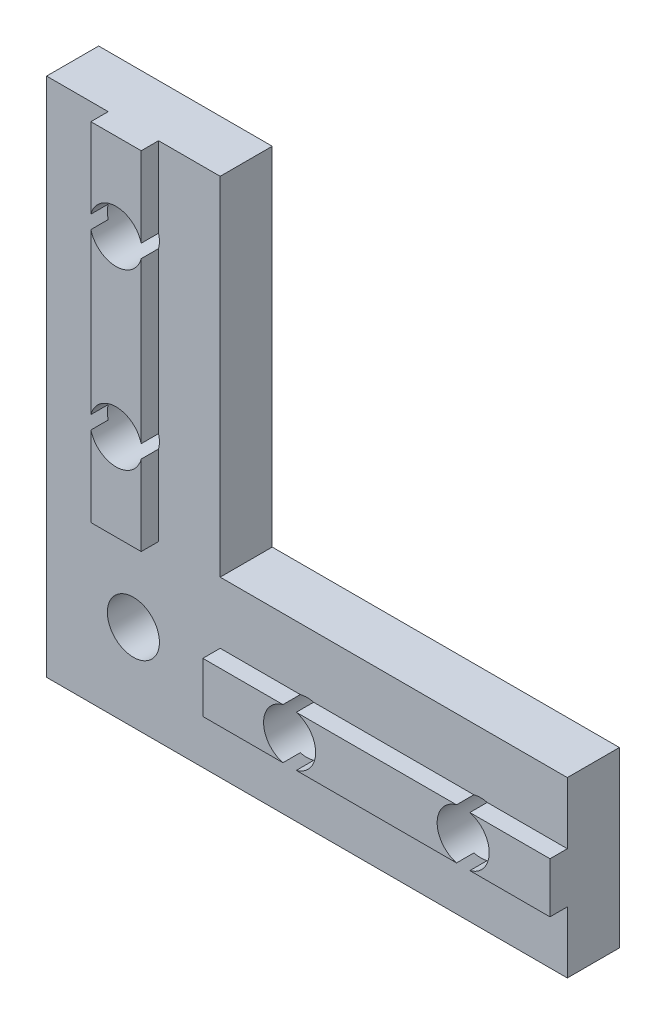
from build123d import *

# Parameters (mm, degrees)
ESQUISSE1_R             = 1.5
BOSS_EXTRU_1_DEPTH      = 3
ESQUISSE2_W             = 2.9
ESQUISSE2_H             = 20
ESQUISSE2_W_2           = 20
ESQUISSE2_H_2           = 2.9
BOSS_EXTRU_2_DEPTH      = 1
ESQUISSE3_R             = 1.5
ENL_V_MAT_EXTRU_1_DEPTH = 5


with BuildPart() as part:
    # Esquisse1 → Boss.-Extru.1 (new body)
    with BuildSketch(Plane.XY):
        Polygon((0, 0), (30, 0), (30, 10), (10, 10), (10, 30), (0, 30), align=None)
        with Locations((5, 25)):
            Circle(ESQUISSE1_R, mode=Mode.SUBTRACT)
        with Locations((5, 15)):
            Circle(ESQUISSE1_R, mode=Mode.SUBTRACT)
        with Locations((5, 5)):
            Circle(ESQUISSE1_R, mode=Mode.SUBTRACT)
        with Locations((15, 5)):
            Circle(ESQUISSE1_R, mode=Mode.SUBTRACT)
        with Locations((25, 5)):
            Circle(ESQUISSE1_R, mode=Mode.SUBTRACT)
    extrude(amount=BOSS_EXTRU_1_DEPTH)

    # Esquisse2 → Boss.-Extru.2 (add)
    with BuildSketch(Plane.XY.offset(3)):
        with Locations((5, 20)):
            Rectangle(ESQUISSE2_W, ESQUISSE2_H)
        with Locations((20, 5)):
            Rectangle(ESQUISSE2_W_2, ESQUISSE2_H_2)
    extrude(amount=BOSS_EXTRU_2_DEPTH)

    # Esquisse3 → Enlèv. mat.-Extru.1 (cut, through all)
    with BuildSketch(Plane.XY.offset(4)):
        with Locations((5, 25)):
            Circle(ESQUISSE3_R)
        with Locations((5, 15)):
            Circle(ESQUISSE3_R)
        with Locations((15, 5)):
            Circle(ESQUISSE3_R)
        with Locations((25, 5)):
            Circle(ESQUISSE3_R)
    extrude(amount=-ENL_V_MAT_EXTRU_1_DEPTH, mode=Mode.SUBTRACT)


solid = part.part
